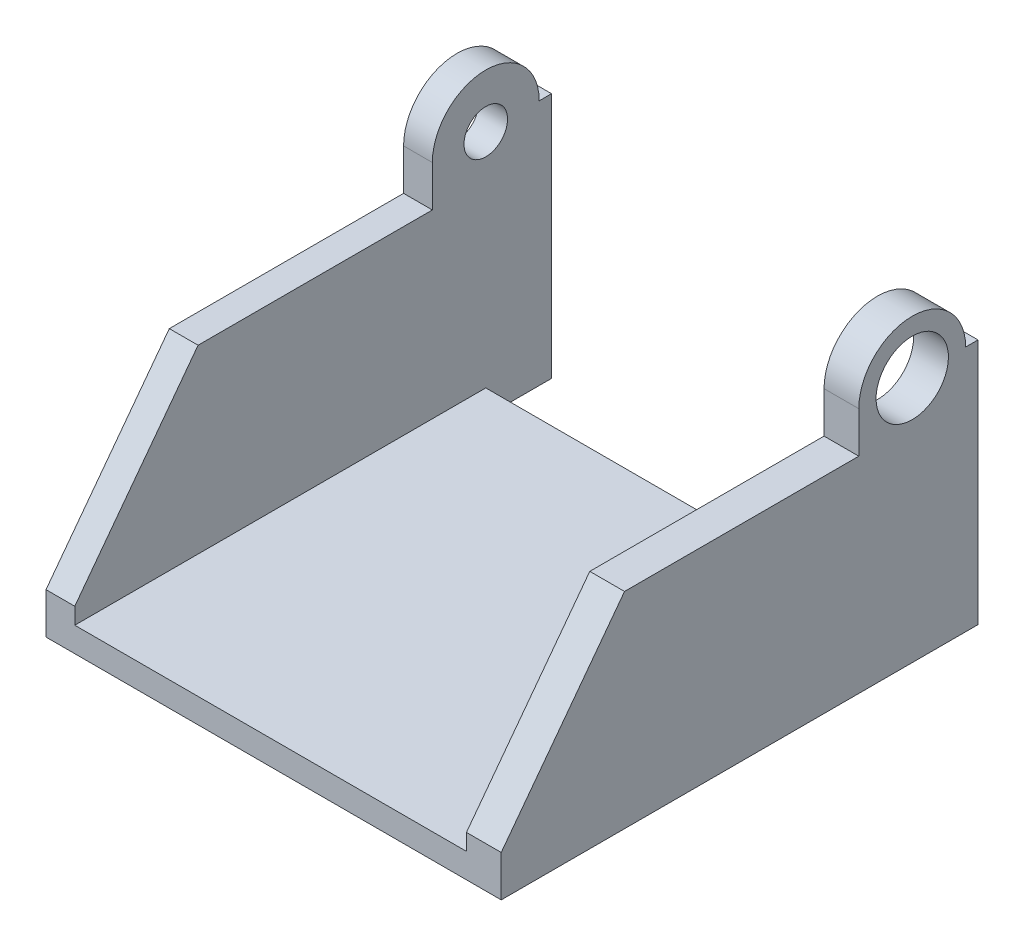
from build123d import *

# Parameters (mm, degrees)
SKETCH1_W               = 3.5
SKETCH1_H               = 30
SKETCH1_W_2             = 23.825
SKETCH1_H_2             = 3
BOSS_EXTRUDE1_DEPTH     = 50
BOSS_EXTRUDE2_DEPTH     = 3.5
CUT_EXTRUDE1_START      = -28.325
SKETCH3_R               = 1.5
CUT_EXTRUDE1_DEPTH      = 29.325
SKETCH4_R               = 2.5
CUT_EXTRUDE2_DEPTH      = 1
CUT_EXTRUDE2_DEPTH_BACK = 3.15
SKETCH5_R               = 2.9
CUT_EXTRUDE3_DEPTH      = 7.15
CUT_EXTRUDE4_DEPTH      = 7.15
SKETCH7_R               = 2.5
SKETCH7_R_2             = 1.5
BOSS_EXTRUDE3_DEPTH     = 0.65
SKETCH9_R               = 6.5
CUT_EXTRUDE5_DEPTH      = 0.4
SKETCH12_R              = 4.4
BOSS_EXTRUDE4_DEPTH     = 1.13
SKETCH13_R              = 2.5
SKETCH13_R_2            = 1.5
BOSS_EXTRUDE5_DEPTH     = 2.5
SKETCH14_R              = 2.65
CUT_EXTRUDE7_DEPTH      = 5.05
SKETCH10_R              = 4.4
CUT_EXTRUDE8_DEPTH      = 10
CUT_EXTRUDE8_DEPTH_BACK = 10


with BuildPart() as part:
    # Sketch1 → Boss-Extrude1 (new body)
    with BuildSketch(Plane.XY):
        with Locations((-25.575, -15)):
            Rectangle(SKETCH1_W, SKETCH1_H)
        with Locations((-11.9125, -28.5)):
            Rectangle(SKETCH1_W_2, SKETCH1_H_2)
    boss_extrude1 = extrude(amount=BOSS_EXTRUDE1_DEPTH)

    # Sketch2 → Boss-Extrude2 (add)
    with BuildSketch(Plane(origin=(-23.825, 0, 0), x_dir=(0, 0, -1), z_dir=(1, 0, 0))):
        with BuildLine():
            Line((8, 0), (6.5, 0))
            ThreePointArc((6.5, 0), (4.596194078, -4.596194078), (0, -6.5))
            Line((0, -6.5), (0, -27))
            Line((0, -27), (0, -30))
            Line((0, -30), (8, -30))
            Line((8, -30), (8, 0))
        make_face()
        with BuildLine():
            Line((6.5, 0), (1.5, 0))
            ThreePointArc((1.5, 0), (1.060660172, -1.060660172), (0, -1.5))
            Line((0, -1.5), (0, -6.5))
            ThreePointArc((0, -6.5), (4.596194078, -4.596194078), (6.5, 0))
        make_face()
        with BuildLine():
            ThreePointArc((-1.5, 0), (0, 1.5), (1.5, 0))
            Line((1.5, 0), (6.5, 0))
            ThreePointArc((6.5, 0), (0, 6.5), (-6.5, 0))
            Line((-6.5, 0), (-1.5, 0))
        make_face()
    boss_extrude2 = extrude(amount=-BOSS_EXTRUDE2_DEPTH)

    # Sketch3 → Cut-Extrude1 (cut)
    with BuildSketch(Plane.ZY.offset(27.325).offset(CUT_EXTRUDE1_START)):
        Circle(SKETCH3_R)
    cut_extrude1 = extrude(amount=CUT_EXTRUDE1_DEPTH, mode=Mode.SUBTRACT)

    # Mirror1: Boss-Extrude1, Boss-Extrude2, Cut-Extrude1 across plane
    add(boss_extrude1.mirror(Plane(origin=(0, 0, 50), x_dir=(0, 0, 1), z_dir=(-1, 0, 0))))
    add(boss_extrude2.mirror(Plane(origin=(0, 0, 50), x_dir=(0, 0, 1), z_dir=(-1, 0, 0))))
    add(cut_extrude1.mirror(Plane(origin=(0, 0, 50), x_dir=(0, 0, 1), z_dir=(-1, 0, 0))), mode=Mode.SUBTRACT)

    # Sketch4 → Cut-Extrude2 (cut, two sides)
    with BuildSketch(Plane.ZY.offset(27.325)) as cut_extrude2_sk:
        Circle(SKETCH4_R)
    extrude(amount=CUT_EXTRUDE2_DEPTH, mode=Mode.SUBTRACT)
    extrude(cut_extrude2_sk.sketch, amount=-CUT_EXTRUDE2_DEPTH_BACK, mode=Mode.SUBTRACT)

    # Sketch5 → Cut-Extrude3 (cut)
    with BuildSketch(Plane(origin=(27.325, 0, 0), x_dir=(0, 0, -1), z_dir=(1, 0, 0))):
        Circle(SKETCH5_R)
    extrude(amount=-CUT_EXTRUDE3_DEPTH, mode=Mode.SUBTRACT)

    # Sketch6 → Cut-Extrude4 (cut)
    with BuildSketch(Plane.ZY.offset(27.325)):
        Polygon((50, 0), (50, -25), (35, -5), (6.5, -5), (6.5, 0), align=None)
    cut_extrude4 = extrude(amount=-CUT_EXTRUDE4_DEPTH, mode=Mode.SUBTRACT)

    # Mirror2: Cut-Extrude4 across plane
    add(cut_extrude4.mirror(Plane(origin=(0, 0, 0), x_dir=(0, 0, 1), z_dir=(1, 0, 0))), mode=Mode.SUBTRACT)

    # Sketch7 → Boss-Extrude3 (add)
    with BuildSketch(Plane.ZY.offset(24.175)):
        Circle(SKETCH7_R)
        Circle(SKETCH7_R_2, mode=Mode.SUBTRACT)
    extrude(amount=BOSS_EXTRUDE3_DEPTH)

    # Sketch9 → Cut-Extrude5 (cut)
    with BuildSketch(Plane(origin=(27.325, 0, 0), x_dir=(0, 0, -1), z_dir=(1, 0, 0))):
        Circle(SKETCH9_R)
        Polygon((8, 0), (-6.5, 0), (-6.5, -3.791432832), (-52.61721684, -3.791432832), (-52.61721684, -30), (-6.5, -30), (8, -30), align=None)
    extrude(amount=-CUT_EXTRUDE5_DEPTH, mode=Mode.SUBTRACT)

    # Sketch12 → Boss-Extrude4 (add)
    with BuildSketch(Plane(origin=(26.925, 0, 0), x_dir=(0, 0, -1), z_dir=(1, 0, 0))):
        with BuildLine():
            Line((8, 0), (6.5, 0))
            ThreePointArc((6.5, 0), (0, 6.5), (-6.5, 0))
            Line((-6.5, 0), (-6.5, -5))
            Line((-6.5, -5), (-35, -5))
            Line((-35, -5), (-50, -25))
            Line((-50, -25), (-50, -30))
            Line((-50, -30), (8, -30))
            Line((8, -30), (8, 0))
        make_face()
        Circle(SKETCH12_R, mode=Mode.SUBTRACT)
    extrude(amount=BOSS_EXTRUDE4_DEPTH)

    # Sketch13 → Boss-Extrude5 (add)
    with BuildSketch(Plane.ZY.offset(27.325)):
        Circle(SKETCH13_R)
        Circle(SKETCH13_R_2, mode=Mode.SUBTRACT)
    extrude(amount=-BOSS_EXTRUDE5_DEPTH)

    # Sketch14 → Cut-Extrude7 (cut)
    with BuildSketch(Plane.ZY.offset(27.325)):
        Circle(SKETCH14_R)
    extrude(amount=-CUT_EXTRUDE7_DEPTH, mode=Mode.SUBTRACT)

    # Sketch10 → Cut-Extrude8 (cut, two sides)
    with BuildSketch(Plane(origin=(26.925, 0, 0), x_dir=(0, 0, -1), z_dir=(1, 0, 0))) as cut_extrude8_sk:
        Circle(SKETCH10_R)
    extrude(amount=CUT_EXTRUDE8_DEPTH, mode=Mode.SUBTRACT)
    extrude(cut_extrude8_sk.sketch, amount=-CUT_EXTRUDE8_DEPTH_BACK, mode=Mode.SUBTRACT)


solid = part.part
